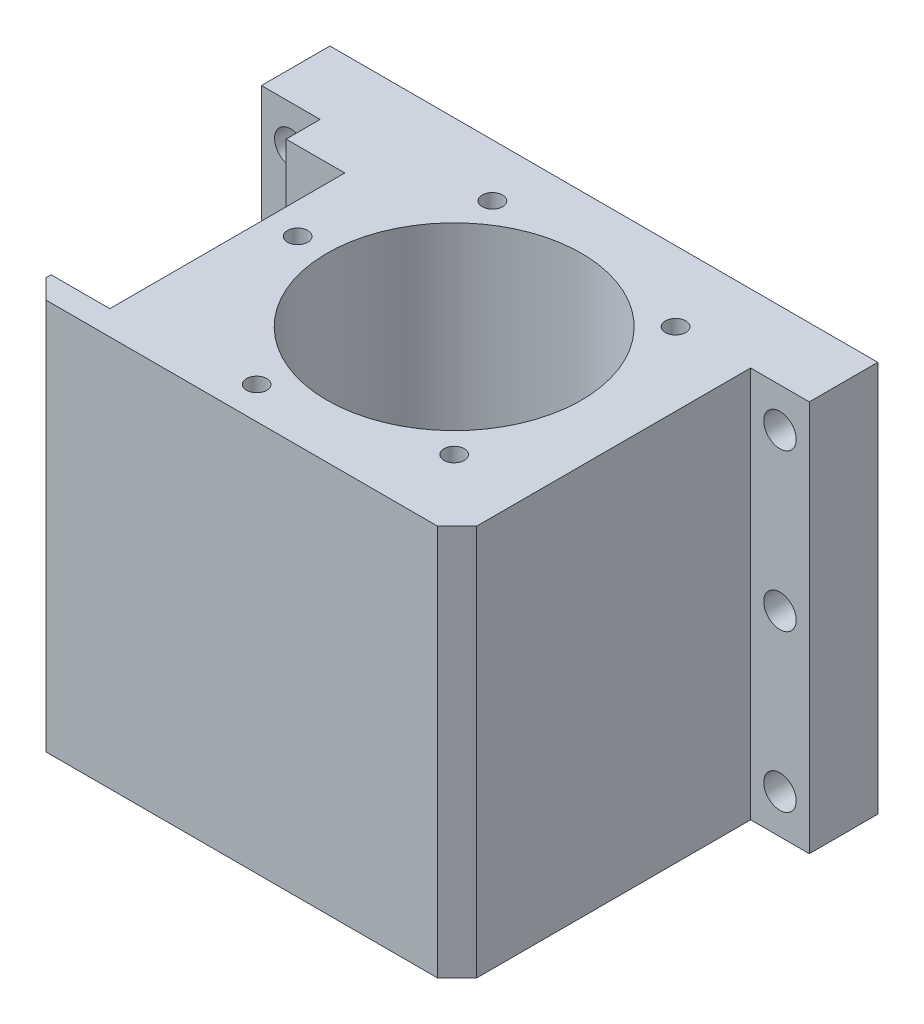
from build123d import *

# Parameters (mm, degrees)
SKETCH_1_W           = 140
SKETCH_1_H           = 100
EXTRUDE_1_DEPTH      = 92.5
SKETCH_2_R           = 32.525
CUT_EXTRUDE_1_DEPTH  = 101
SKETCH_3_OUTSIDE_W   = 181.068
SKETCH_3_OUTSIDE_H   = 141.068
SKETCH_3_OUTSIDE_W_2 = 110
SKETCH_3_OUTSIDE_H_2 = 100
CUT_EXTRUDE_2_DEPTH  = 75
SKETCH_5_W           = 60.05
SKETCH_5_H           = 100
CUT_EXTRUDE_3_DEPTH  = 15
CHAMFER_2_SIZE       = 5
SKETCH_6_R           = 2.6
CUT_EXTRUDE_4_DEPTH  = 20
SKETCH_9_R           = 4.15
CUT_EXTRUDE_5_DEPTH  = 18.5
SKETCH_10_R          = 2.6
CUT_EXTRUDE_6_DEPTH  = 20


with BuildPart() as part:
    # 草图1 → 凸台-拉伸1 (new body)
    with BuildSketch(Plane.XY):
        with Locations((70, -50)):
            Rectangle(SKETCH_1_W, SKETCH_1_H)
    extrude(amount=EXTRUDE_1_DEPTH)

    # 草图2 → 切除-拉伸1 (cut, through all)
    with BuildSketch(Plane(origin=(0, 0, 0), x_dir=(1, 0, 0), z_dir=(0, 1, 0))):
        with Locations((78, -46.25)):
            Circle(SKETCH_2_R)
    extrude(amount=-CUT_EXTRUDE_1_DEPTH, mode=Mode.SUBTRACT)

    # 草图3 outside → 切除-拉伸2 (cut)
    with BuildSketch(Plane.XY.offset(92.5)):
        with Locations((70, -50)):
            Rectangle(SKETCH_3_OUTSIDE_W, SKETCH_3_OUTSIDE_H)
        with Locations((70, -50)):
            Rectangle(SKETCH_3_OUTSIDE_W_2, SKETCH_3_OUTSIDE_H_2, mode=Mode.SUBTRACT)
    extrude(amount=-CUT_EXTRUDE_2_DEPTH, mode=Mode.SUBTRACT)

    # 草图5 → 切除-拉伸3 (cut)
    with BuildSketch(Plane.ZY.offset(-15)):
        with Locations((56.225, -50)):
            Rectangle(SKETCH_5_W, SKETCH_5_H)
    extrude(amount=-CUT_EXTRUDE_3_DEPTH, mode=Mode.SUBTRACT)

    # 倒角2
    chamfer_2_edges = [part.edges().sort_by_distance(p)[0] for p in [
        (15, -50, 92.5),
        (125, -50, 92.5),
    ]]
    chamfer(chamfer_2_edges, length=CHAMFER_2_SIZE)

    # 草图6 → 切除-拉伸4 (cut)
    with BuildSketch(Plane.XZ.offset(100)):
        with Locations((78, 85.75)):
            Circle(SKETCH_6_R)
        with Locations((112.208003449, 66)):
            Circle(SKETCH_6_R)
        with Locations((112.208003449, 26.5)):
            Circle(SKETCH_6_R)
        with Locations((78, 6.75)):
            Circle(SKETCH_6_R)
        with Locations((43.791996551, 26.5)):
            Circle(SKETCH_6_R)
        with Locations((43.791996551, 66)):
            Circle(SKETCH_6_R)
    extrude(amount=-CUT_EXTRUDE_4_DEPTH, mode=Mode.SUBTRACT)

    # 草图9 → 切除-拉伸5 (cut, through all)
    with BuildSketch(Plane.XY.offset(17.5)):
        with Locations((7.5, -10)):
            Circle(SKETCH_9_R)
        with Locations((132.5, -10)):
            Circle(SKETCH_9_R)
        with Locations((132.5, -50)):
            Circle(SKETCH_9_R)
        with Locations((132.5, -90)):
            Circle(SKETCH_9_R)
        with Locations((7.5, -50)):
            Circle(SKETCH_9_R)
        with Locations((7.5, -90)):
            Circle(SKETCH_9_R)
    extrude(amount=-CUT_EXTRUDE_5_DEPTH, mode=Mode.SUBTRACT)

    # 草图10 → 切除-拉伸6 (cut)
    with BuildSketch(Plane(origin=(0, 0, 0), x_dir=(1, 0, 0), z_dir=(0, 1, 0))):
        with Locations((106.284271247, -17.965728753)):
            Circle(SKETCH_10_R)
        with Locations((106.284271247, -74.534271247)):
            Circle(SKETCH_10_R)
        with Locations((38, -46.25)):
            Circle(SKETCH_10_R)
        with Locations((65.534490363, -84.258039538)):
            Circle(SKETCH_10_R)
        with Locations((55.025808003, -13.505740929)):
            Circle(SKETCH_10_R)
    extrude(amount=-CUT_EXTRUDE_6_DEPTH, mode=Mode.SUBTRACT)


solid = part.part
